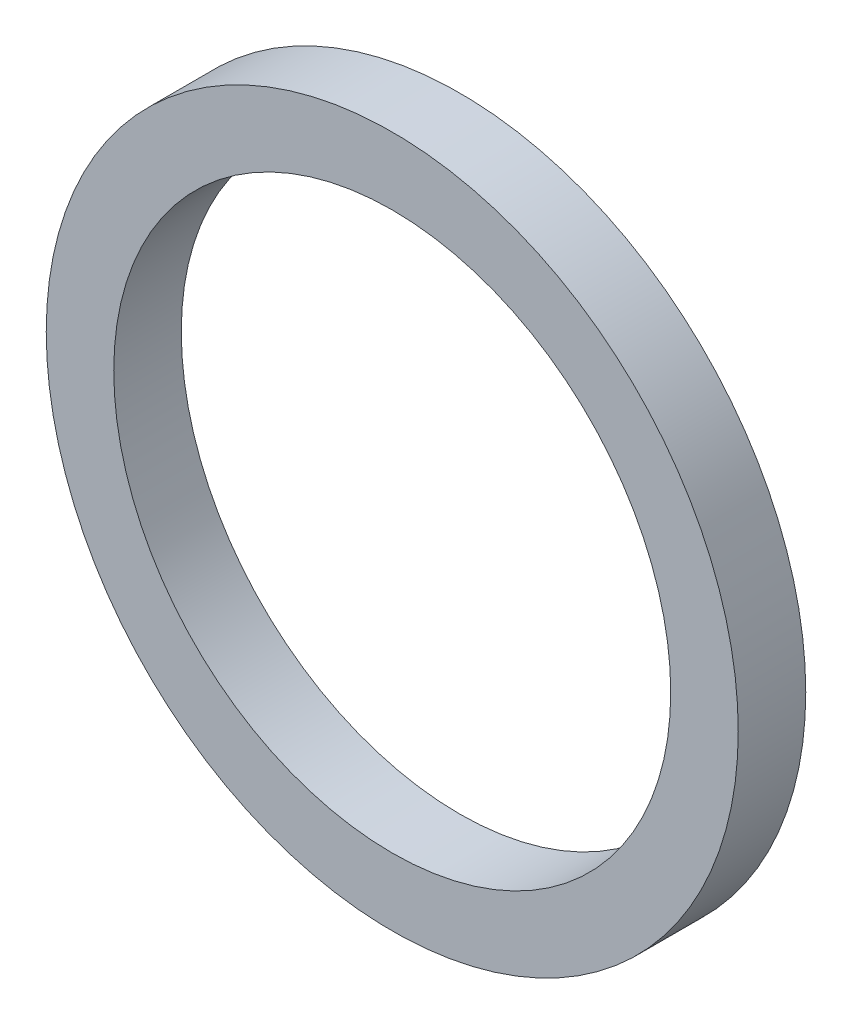
from build123d import *

# Parameters (mm, degrees)
SKETCH_1_R      = 10.25
SKETCH_1_R_2    = 8.25
EXTRUDE_1_DEPTH = 2


with BuildPart() as part:
    # ｽｹｯﾁ1 → ﾎﾞｽ - 押し出し1 (new body)
    with BuildSketch(Plane.XY):
        Circle(SKETCH_1_R)
        Circle(SKETCH_1_R_2, mode=Mode.SUBTRACT)
    extrude(amount=EXTRUDE_1_DEPTH)


solid = part.part
